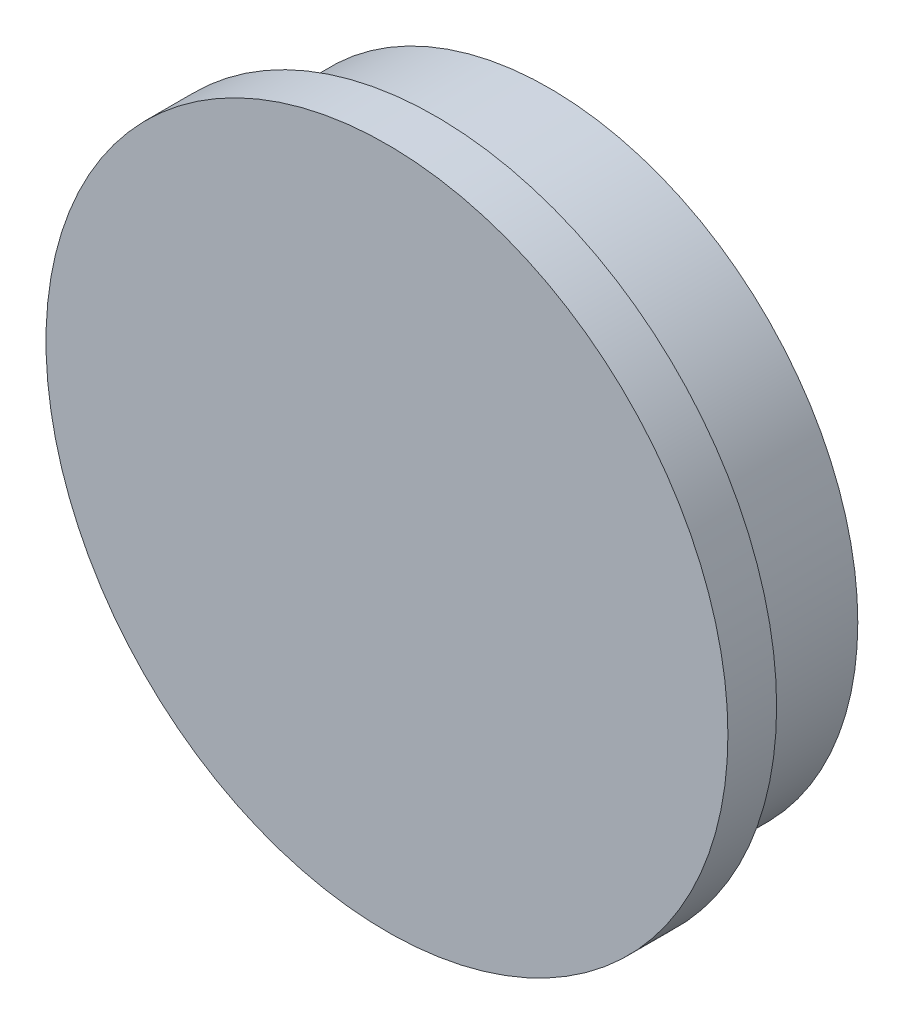
from build123d import *


with BuildPart() as part:
    # Эскиз2 → Повернуть1 (revolve)
    with BuildSketch(Plane(origin=(0, 0, 0), x_dir=(0, 0, -1), z_dir=(1, 0, 0))):
        Polygon((0, 0), (0, 21), (3, 21), (3, 19), (10, 19), (10, 0), align=None)
    revolve(axis=Axis((0, 0, 0), (0, 0, -1)))


solid = part.part
